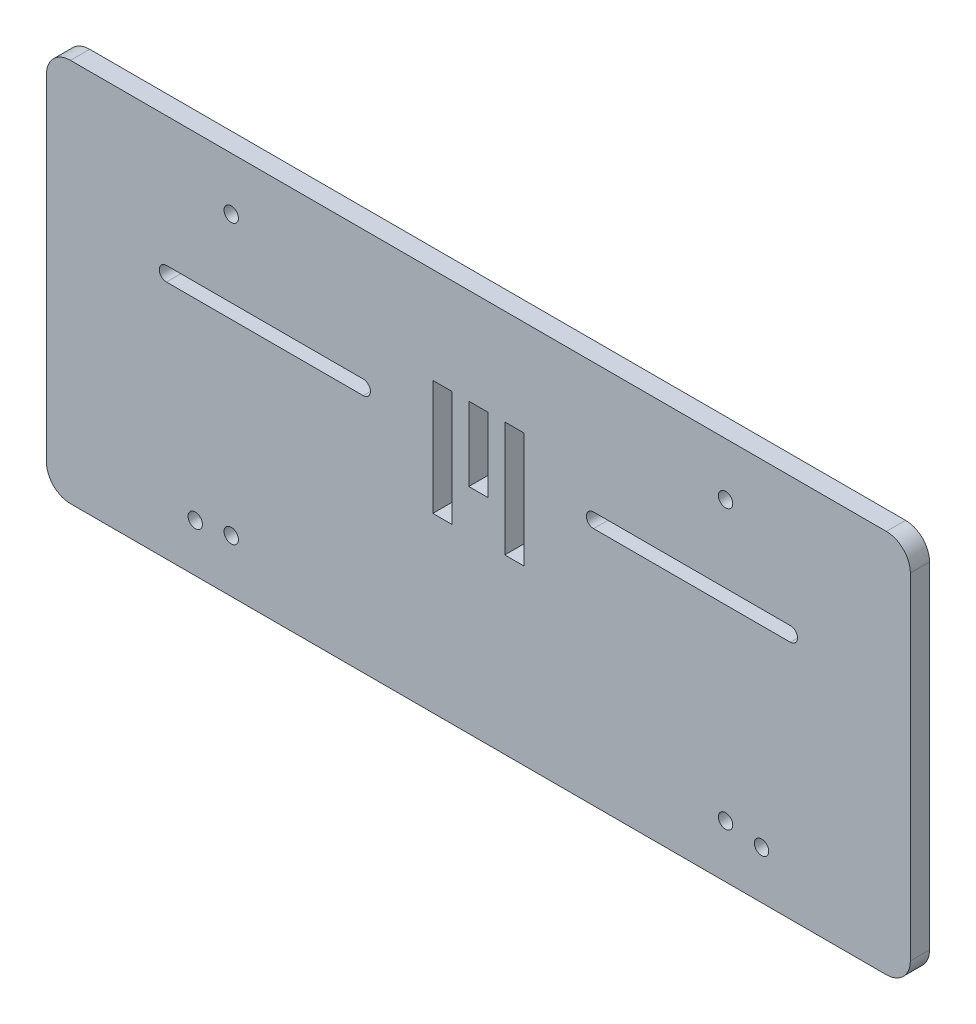
from build123d import *

# Parameters (mm, degrees)
SKETCH1_W           = 180
SKETCH1_H           = 80
SKETCH1_R           = 1.5
BOSS_EXTRUDE1_DEPTH = 4
SKETCH2_W           = 4
SKETCH2_H           = 24
SKETCH2_H_2         = 15.4
CUT_EXTRUDE1_DEPTH  = 4
FILLET1_R           = 5


with BuildPart() as part:
    # Sketch1 → Boss-Extrude1 (new body)
    with BuildSketch(Plane.XY):
        with Locations((2.700642055, -21.117125984)):
            Rectangle(SKETCH1_W, SKETCH1_H)
        with Locations((61.700642055, -51.117125984)):
            Circle(SKETCH1_R, mode=Mode.SUBTRACT)
        with Locations((-56.299357945, -51.117125984)):
            Circle(SKETCH1_R, mode=Mode.SUBTRACT)
        with Locations((-48.799357945, 7.882874016)):
            Circle(SKETCH1_R, mode=Mode.SUBTRACT)
        with Locations((54.200642055, 7.882874016)):
            Circle(SKETCH1_R, mode=Mode.SUBTRACT)
        with Locations((54.200642055, -50.117125984)):
            Circle(SKETCH1_R, mode=Mode.SUBTRACT)
        with Locations((-48.799357945, -50.117125984)):
            Circle(SKETCH1_R, mode=Mode.SUBTRACT)
        with BuildLine():
            Line((-62.299357945, -8.117125984), (-21.299357945, -8.117125984))
            ThreePointArc((-21.299357945, -8.117125984), (-19.799357945, -9.617125984), (-21.299357945, -11.117125984))
            Line((-21.299357945, -11.117125984), (-62.299357945, -11.117125984))
            ThreePointArc((-62.299357945, -11.117125984), (-63.799357945, -9.617125984), (-62.299357945, -8.117125984))
        make_face(mode=Mode.SUBTRACT)
        with BuildLine():
            Line((26.700642055, -8.117125984), (67.700642055, -8.117125984))
            ThreePointArc((67.700642055, -8.117125984), (69.200642055, -9.617125984), (67.700642055, -11.117125984))
            Line((67.700642055, -11.117125984), (26.700642055, -11.117125984))
            ThreePointArc((26.700642055, -11.117125984), (25.200642055, -9.617125984), (26.700642055, -8.117125984))
        make_face(mode=Mode.SUBTRACT)
    extrude(amount=BOSS_EXTRUDE1_DEPTH)

    # Sketch2 → Cut-Extrude1 (cut)
    with BuildSketch(Plane.XY.offset(4)):
        with Locations((-4.799357945, -13.117125984)):
            Rectangle(SKETCH2_W, SKETCH2_H)
        with Locations((2.700642055, -8.817125984)):
            Rectangle(SKETCH2_W, SKETCH2_H_2)
        with Locations((10.200642055, -13.117125984)):
            Rectangle(SKETCH2_W, SKETCH2_H)
    extrude(amount=-CUT_EXTRUDE1_DEPTH, mode=Mode.SUBTRACT)

    # Fillet1
    fillet1_edges = [part.edges().sort_by_distance(p)[0] for p in [
        (-87.299357945, 18.882874016, 2),
        (92.700642055, 18.882874016, 2),
        (92.700642055, -61.117125984, 2),
        (-87.299357945, -61.117125984, 2),
    ]]
    fillet(fillet1_edges, radius=FILLET1_R)


solid = part.part
